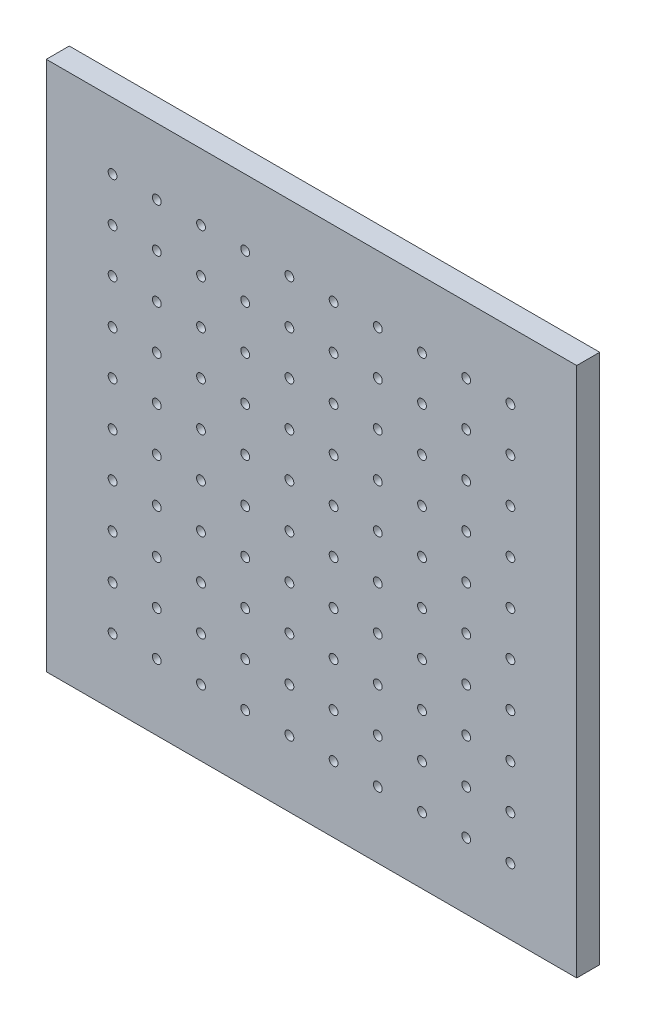
from build123d import *

# Parameters (mm, degrees)
SKETCH_1_W                  = 300
SKETCH_1_H                  = 300
EXTRUDE_1_DEPTH             = 13
HOLE_WIZARD_M6_1_D          = 5
PATTERN_LINEAR_1_COUNT      = 10
PATTERN_LINEAR_1_PITCH      = 25
PATTERN_LINEAR_1_COUNT_DIR2 = 10
PATTERN_LINEAR_1_PITCH_DIR2 = 25


with BuildPart() as part:
    # 草图1 → 凸台-拉伸1 (new body)
    with BuildSketch(Plane.XY):
        Rectangle(SKETCH_1_W, SKETCH_1_H)
    extrude(amount=EXTRUDE_1_DEPTH)

    # M6 螺纹孔的螺纹孔钻头1 (through all)
    with Locations(Plane.XY.offset(13)):
        with Locations((-112.5, -112.5)):
            hole_wizard_m6_1 = Hole(HOLE_WIZARD_M6_1_D / 2)

    # 阵列(线性)1: Hole Wizard M6 _1 10 × 10
    with Locations(*[(j * PATTERN_LINEAR_1_PITCH_DIR2, i * PATTERN_LINEAR_1_PITCH, 0) for i in range(PATTERN_LINEAR_1_COUNT) for j in range(PATTERN_LINEAR_1_COUNT_DIR2) if (i, j) != (0, 0)]):
        add(hole_wizard_m6_1, mode=Mode.SUBTRACT)


solid = part.part
